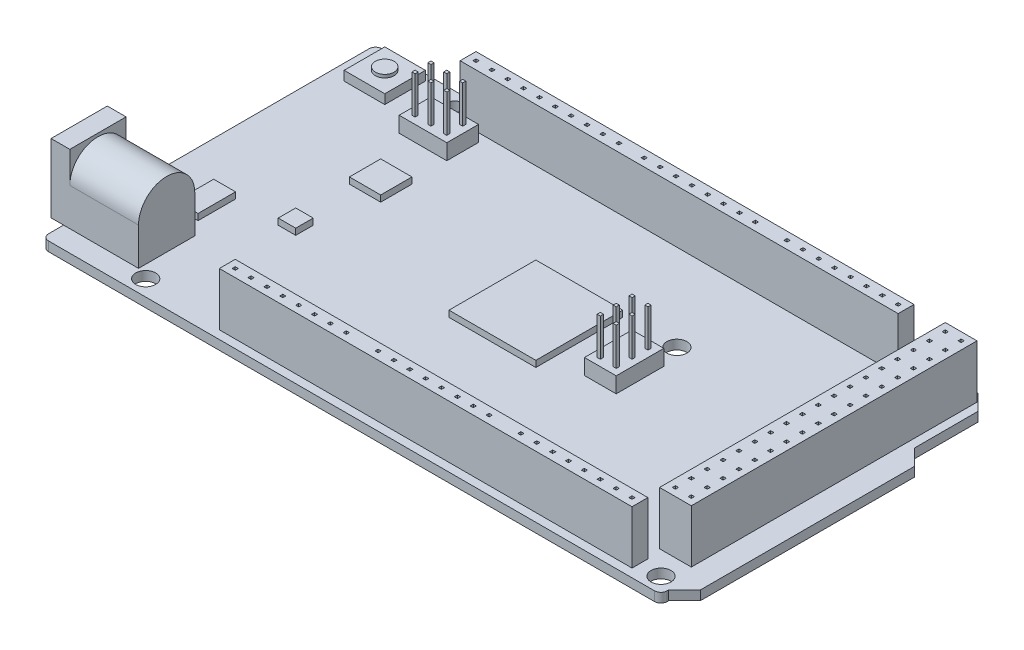
from build123d import *

# Parameters (mm, degrees)
BOSS_EXTRUDE1_DEPTH      = 1.5
FILLET1_R                = 1
SKETCH2_R                = 1.6
CUT_EXTRUDE1_DEPTH       = 59.477289609
SKETCH3_W                = 5.08
SKETCH3_H                = 45.72
BOSS_EXTRUDE2_DEPTH      = 8.5
SKETCH4_W                = 0.5
SKETCH4_H                = 0.5
CUT_EXTRUDE2_DEPTH       = 7
SKETCH6_W                = 9
SKETCH6_H                = 11
BOSS_EXTRUDE4_DEPTH      = 2
BOSS_EXTRUDE4_DEPTH_BACK = 1
SKETCH7_R                = 4.5
BOSS_EXTRUDE5_DEPTH      = 11
SKETCH8_W                = 11
SKETCH8_H                = 9
BOSS_EXTRUDE6_DEPTH      = 6
SKETCH11_W               = 13.9
SKETCH11_H               = 13.9
SKETCH11_W_2             = 5
SKETCH11_H_2             = 5
SKETCH11_W_3             = 2.8
SKETCH11_H_3             = 2.8
SKETCH11_W_4             = 3.5
SKETCH11_H_4             = 6
BOSS_EXTRUDE8_DEPTH      = 1
SKETCH12_R               = 3
CUT_EXTRUDE4_DEPTH       = 9.5
SKETCH13_R               = 1.25
BOSS_EXTRUDE9_DEPTH      = 7.5
FILLET2_R                = 1
SKETCH14_W               = 6.5
SKETCH14_H               = 6.5
BOSS_EXTRUDE10_DEPTH     = 1.5
SKETCH15_R               = 1.5
BOSS_EXTRUDE11_DEPTH     = 0.5
SKETCH16_W               = 5.08
SKETCH16_H               = 7.62
SKETCH16_W_2             = 7.62
SKETCH16_H_2             = 5.08
BOSS_EXTRUDE12_DEPTH     = 2.5
SKETCH17_W               = 0.5
SKETCH17_H               = 0.5
BOSS_EXTRUDE13_DEPTH     = 6


with BuildPart() as part:
    # Sketch1 → Boss-Extrude1 (new body)
    with BuildSketch(Plane(origin=(0, 0, 0), x_dir=(1, 0, 0), z_dir=(0, 1, 0))):
        Polygon((49.49, 24.11), (49.49, 13.95), (52.03, 11.41), (52.03, -22.85), (49.49, -25.39), (49.49, -26.65), (-49.49, -26.65), (-49.49, 26.65), (46.95, 26.65), align=None)
    extrude(amount=BOSS_EXTRUDE1_DEPTH)

    # Fillet1
    fillet1_edges = [part.edges().sort_by_distance(p)[0] for p in [
        (-49.49, 0.75, -26.65),
        (49.49, 0.75, 26.65),
        (-49.49, 0.75, 26.65),
    ]]
    fillet(fillet1_edges, radius=FILLET1_R)

    # Sketch2 → Cut-Extrude1 (cut, through all)
    with BuildSketch(Plane(origin=(0, 1.5, 0), x_dir=(1, 0, 0), z_dir=(0, 1, 0))):
        with Locations(Location((46.98, -24.11, 0), (0, 0, 270))):
            Circle(SKETCH2_R)
        with Locations(Location((40.62, 24.11, 0), (0, 0, 270))):
            Circle(SKETCH2_R)
        with Locations(Location((-34.26, 24.11, 0), (0, 0, 270))):
            Circle(SKETCH2_R)
        with Locations(Location((-35.49, -24.11, 0), (0, 0, 270))):
            Circle(SKETCH2_R)
        with Locations(Location((16.53, -19.03, 0), (0, 0, 270))):
            Circle(SKETCH2_R)
        with Locations(Location((16.53, 8.88, 0), (0, 0, 270))):
            Circle(SKETCH2_R)
    extrude(amount=-CUT_EXTRUDE1_DEPTH, mode=Mode.SUBTRACT)

    # Sketch3 → Boss-Extrude2 (add)
    with BuildSketch(Plane(origin=(0, 1.5, 0), x_dir=(1, 0, 0), z_dir=(0, 1, 0))):
        Polygon((-22.51, -22.76), (-2.19, -22.76), (0.35, -22.76), (20.67, -22.76), (23.21, -22.76), (43.53, -22.76), (43.53, -25.3), (23.21, -25.3), (20.67, -25.3), (0.35, -25.3), (-2.19, -25.3), (-22.51, -25.3), align=None)
        with Locations((45.6, 2.44)):
            Rectangle(SKETCH3_W, SKETCH3_H)
        Polygon((38.06, 25.3), (17.74, 25.3), (15.2, 25.3), (-5.12, 25.3), (-6.64, 25.3), (-32.04, 25.3), (-32.04, 22.76), (-6.64, 22.76), (-5.12, 22.76), (15.2, 22.76), (17.74, 22.76), (38.06, 22.76), align=None)
    extrude(amount=BOSS_EXTRUDE2_DEPTH)

    # Sketch4 → Cut-Extrude2 (cut)
    with BuildSketch(Plane(origin=(0, 10, 0), x_dir=(1, 0, 0), z_dir=(0, 1, 0))):
        with Locations((-21.24, -24.03)):
            Rectangle(SKETCH4_W, SKETCH4_H)
        with Locations((-18.7, -24.03)):
            Rectangle(SKETCH4_W, SKETCH4_H)
        with Locations((-16.16, -24.03)):
            Rectangle(SKETCH4_W, SKETCH4_H)
        with Locations((-13.62, -24.03)):
            Rectangle(SKETCH4_W, SKETCH4_H)
        with Locations((-11.08, -24.03)):
            Rectangle(SKETCH4_W, SKETCH4_H)
        with Locations((-8.54, -24.03)):
            Rectangle(SKETCH4_W, SKETCH4_H)
        with Locations((-6, -24.03)):
            Rectangle(SKETCH4_W, SKETCH4_H)
        with Locations((-3.46, -24.03)):
            Rectangle(SKETCH4_W, SKETCH4_H)
        with Locations((1.62, -24.03)):
            Rectangle(SKETCH4_W, SKETCH4_H)
        with Locations((4.16, -24.03)):
            Rectangle(SKETCH4_W, SKETCH4_H)
        with Locations((6.7, -24.03)):
            Rectangle(SKETCH4_W, SKETCH4_H)
        with Locations((9.24, -24.03)):
            Rectangle(SKETCH4_W, SKETCH4_H)
        with Locations((11.78, -24.03)):
            Rectangle(SKETCH4_W, SKETCH4_H)
        with Locations((14.32, -24.03)):
            Rectangle(SKETCH4_W, SKETCH4_H)
        with Locations((16.86, -24.03)):
            Rectangle(SKETCH4_W, SKETCH4_H)
        with Locations((19.4, -24.03)):
            Rectangle(SKETCH4_W, SKETCH4_H)
        with Locations((24.48, -24.03)):
            Rectangle(SKETCH4_W, SKETCH4_H)
        with Locations((27.02, -24.03)):
            Rectangle(SKETCH4_W, SKETCH4_H)
        with Locations((29.56, -24.03)):
            Rectangle(SKETCH4_W, SKETCH4_H)
        with Locations((32.1, -24.03)):
            Rectangle(SKETCH4_W, SKETCH4_H)
        with Locations((34.64, -24.03)):
            Rectangle(SKETCH4_W, SKETCH4_H)
        with Locations((37.18, -24.03)):
            Rectangle(SKETCH4_W, SKETCH4_H)
        with Locations((39.72, -24.03)):
            Rectangle(SKETCH4_W, SKETCH4_H)
        with Locations((42.26, -24.03)):
            Rectangle(SKETCH4_W, SKETCH4_H)
        with Locations((46.87, -19.15)):
            Rectangle(SKETCH4_W, SKETCH4_H)
        with Locations((44.33, -19.15)):
            Rectangle(SKETCH4_W, SKETCH4_H)
        with Locations((46.87, -16.61)):
            Rectangle(SKETCH4_W, SKETCH4_H)
        with Locations((44.33, -16.61)):
            Rectangle(SKETCH4_W, SKETCH4_H)
        with Locations((46.87, -14.07)):
            Rectangle(SKETCH4_W, SKETCH4_H)
        with Locations((44.33, -14.07)):
            Rectangle(SKETCH4_W, SKETCH4_H)
        with Locations((46.87, -11.53)):
            Rectangle(SKETCH4_W, SKETCH4_H)
        with Locations((44.33, -11.53)):
            Rectangle(SKETCH4_W, SKETCH4_H)
        with Locations((46.87, -8.99)):
            Rectangle(SKETCH4_W, SKETCH4_H)
        with Locations((44.33, -8.99)):
            Rectangle(SKETCH4_W, SKETCH4_H)
        with Locations((46.87, -6.45)):
            Rectangle(SKETCH4_W, SKETCH4_H)
        with Locations((44.33, -6.45)):
            Rectangle(SKETCH4_W, SKETCH4_H)
        with Locations((46.87, -3.91)):
            Rectangle(SKETCH4_W, SKETCH4_H)
        with Locations((44.33, -3.91)):
            Rectangle(SKETCH4_W, SKETCH4_H)
        with Locations((46.87, -1.37)):
            Rectangle(SKETCH4_W, SKETCH4_H)
        with Locations((44.33, -1.37)):
            Rectangle(SKETCH4_W, SKETCH4_H)
        with Locations((46.87, 1.17)):
            Rectangle(SKETCH4_W, SKETCH4_H)
        with Locations((44.33, 1.17)):
            Rectangle(SKETCH4_W, SKETCH4_H)
        with Locations((46.87, 3.71)):
            Rectangle(SKETCH4_W, SKETCH4_H)
        with Locations((44.33, 3.71)):
            Rectangle(SKETCH4_W, SKETCH4_H)
        with Locations((46.87, 6.25)):
            Rectangle(SKETCH4_W, SKETCH4_H)
        with Locations((44.33, 6.25)):
            Rectangle(SKETCH4_W, SKETCH4_H)
        with Locations((46.87, 8.79)):
            Rectangle(SKETCH4_W, SKETCH4_H)
        with Locations((44.33, 8.79)):
            Rectangle(SKETCH4_W, SKETCH4_H)
        with Locations((46.87, 11.33)):
            Rectangle(SKETCH4_W, SKETCH4_H)
        with Locations((44.33, 11.33)):
            Rectangle(SKETCH4_W, SKETCH4_H)
        with Locations((46.87, 13.87)):
            Rectangle(SKETCH4_W, SKETCH4_H)
        with Locations((44.33, 13.87)):
            Rectangle(SKETCH4_W, SKETCH4_H)
        with Locations((46.87, 16.41)):
            Rectangle(SKETCH4_W, SKETCH4_H)
        with Locations((44.33, 16.41)):
            Rectangle(SKETCH4_W, SKETCH4_H)
        with Locations((46.87, 18.95)):
            Rectangle(SKETCH4_W, SKETCH4_H)
        with Locations((44.33, 18.95)):
            Rectangle(SKETCH4_W, SKETCH4_H)
        with Locations((46.87, 21.49)):
            Rectangle(SKETCH4_W, SKETCH4_H)
        with Locations((44.33, 21.49)):
            Rectangle(SKETCH4_W, SKETCH4_H)
        with Locations((46.87, 24.03)):
            Rectangle(SKETCH4_W, SKETCH4_H)
        with Locations((44.33, 24.03)):
            Rectangle(SKETCH4_W, SKETCH4_H)
        with Locations((36.79, 24.03)):
            Rectangle(SKETCH4_W, SKETCH4_H)
        with Locations((34.25, 24.03)):
            Rectangle(SKETCH4_W, SKETCH4_H)
        with Locations((31.71, 24.03)):
            Rectangle(SKETCH4_W, SKETCH4_H)
        with Locations((29.17, 24.03)):
            Rectangle(SKETCH4_W, SKETCH4_H)
        with Locations((26.63, 24.03)):
            Rectangle(SKETCH4_W, SKETCH4_H)
        with Locations((24.09, 24.03)):
            Rectangle(SKETCH4_W, SKETCH4_H)
        with Locations((21.55, 24.03)):
            Rectangle(SKETCH4_W, SKETCH4_H)
        with Locations((19.01, 24.03)):
            Rectangle(SKETCH4_W, SKETCH4_H)
        with Locations((13.93, 24.03)):
            Rectangle(SKETCH4_W, SKETCH4_H)
        with Locations((11.39, 24.03)):
            Rectangle(SKETCH4_W, SKETCH4_H)
        with Locations((8.85, 24.03)):
            Rectangle(SKETCH4_W, SKETCH4_H)
        with Locations((6.31, 24.03)):
            Rectangle(SKETCH4_W, SKETCH4_H)
        with Locations((3.77, 24.03)):
            Rectangle(SKETCH4_W, SKETCH4_H)
        with Locations((1.23, 24.03)):
            Rectangle(SKETCH4_W, SKETCH4_H)
        with Locations((-1.31, 24.03)):
            Rectangle(SKETCH4_W, SKETCH4_H)
        with Locations((-3.85, 24.03)):
            Rectangle(SKETCH4_W, SKETCH4_H)
        with Locations((-7.91, 24.03)):
            Rectangle(SKETCH4_W, SKETCH4_H)
        with Locations((-10.45, 24.03)):
            Rectangle(SKETCH4_W, SKETCH4_H)
        with Locations((-12.99, 24.03)):
            Rectangle(SKETCH4_W, SKETCH4_H)
        with Locations((-15.53, 24.03)):
            Rectangle(SKETCH4_W, SKETCH4_H)
        with Locations((-18.07, 24.03)):
            Rectangle(SKETCH4_W, SKETCH4_H)
        with Locations((-20.61, 24.03)):
            Rectangle(SKETCH4_W, SKETCH4_H)
        with Locations((-23.15, 24.03)):
            Rectangle(SKETCH4_W, SKETCH4_H)
        with Locations((-25.69, 24.03)):
            Rectangle(SKETCH4_W, SKETCH4_H)
        with Locations((-28.23, 24.03)):
            Rectangle(SKETCH4_W, SKETCH4_H)
        with Locations((-30.77, 24.03)):
            Rectangle(SKETCH4_W, SKETCH4_H)
    extrude(amount=-CUT_EXTRUDE2_DEPTH, mode=Mode.SUBTRACT)



with BuildPart() as body_2:
    # Sketch6 → Boss-Extrude4 (new, two sides)
    with BuildSketch(Plane.ZY.offset(49.49)) as boss_extrude4_sk:
        with Locations((18.75, 7)):
            Rectangle(SKETCH6_W, SKETCH6_H)
    extrude(amount=BOSS_EXTRUDE4_DEPTH)
    extrude(boss_extrude4_sk.sketch, amount=-BOSS_EXTRUDE4_DEPTH_BACK)


with BuildPart() as part_1:
    add(part.part)

    add(body_2.part)  # Boss-Extrude5 merges body 2
    # Sketch7 → Boss-Extrude5 (add)
    with BuildSketch(Plane(origin=(-48.49, 0, 0), x_dir=(0, 0, -1), z_dir=(1, 0, 0))):
        with Locations((-18.75, 7.5)):
            Circle(SKETCH7_R)
    extrude(amount=BOSS_EXTRUDE5_DEPTH)

    # Sketch8 → Boss-Extrude6 (add)
    with BuildSketch(Plane(origin=(0, 1.5, 0), x_dir=(1, 0, 0), z_dir=(0, 1, 0))):
        with Locations((-42.99, -18.75)):
            Rectangle(SKETCH8_W, SKETCH8_H)
    extrude(amount=BOSS_EXTRUDE6_DEPTH)

    # Sketch11 → Boss-Extrude8 (add)
    with BuildSketch(Plane(origin=(0, 1.5, 0), x_dir=(1, 0, 0), z_dir=(0, 1, 0))):
        with Locations((1.09, 1.75)):
            Rectangle(SKETCH11_W, SKETCH11_H)
        with Locations((-29.79, 7.8)):
            Rectangle(SKETCH11_W_2, SKETCH11_H_2)
        with Locations((-30.89, -4.7)):
            Rectangle(SKETCH11_W_3, SKETCH11_H_3)
        with Locations((-41.090307387, -8.878300353)):
            Rectangle(SKETCH11_W_4, SKETCH11_H_4)
    extrude(amount=BOSS_EXTRUDE8_DEPTH)

    # Sketch12 → Cut-Extrude4 (cut)
    with BuildSketch(Plane.ZY.offset(51.49)):
        with Locations((18.75, 8)):
            Circle(SKETCH12_R)
    extrude(amount=-CUT_EXTRUDE4_DEPTH, mode=Mode.SUBTRACT)

    # Sketch13 → Boss-Extrude9 (add)
    with BuildSketch(Plane.ZY.offset(41.99)):
        with Locations((18.75, 8)):
            Circle(SKETCH13_R)
    extrude(amount=BOSS_EXTRUDE9_DEPTH)

    # Fillet2
    fillet2_edges = [part_1.edges().sort_by_distance(p)[0] for p in [
        (-49.49, 8, 17.5),
    ]]
    fillet(fillet2_edges, radius=FILLET2_R)

    # Sketch14 → Boss-Extrude10 (add)
    with BuildSketch(Plane(origin=(0, 1.5, 0), x_dir=(1, 0, 0), z_dir=(0, 1, 0))):
        with Locations((-43.74, 22.4)):
            Rectangle(SKETCH14_W, SKETCH14_H)
    extrude(amount=BOSS_EXTRUDE10_DEPTH)

    # Sketch15 → Boss-Extrude11 (add)
    with BuildSketch(Plane(origin=(0, 3, 0), x_dir=(1, 0, 0), z_dir=(0, 1, 0))):
        with Locations(Location((-43.74, 22.4, 0), (0, 0, 270))):
            Circle(SKETCH15_R)
    extrude(amount=BOSS_EXTRUDE11_DEPTH)

    # Sketch16 → Boss-Extrude12 (add)
    with BuildSketch(Plane(origin=(0, 1.5, 0), x_dir=(1, 0, 0), z_dir=(0, 1, 0))):
        with Locations((15.58, 1.39)):
            Rectangle(SKETCH16_W, SKETCH16_H)
        with Locations((-31.55, 18.87)):
            Rectangle(SKETCH16_W_2, SKETCH16_H_2)
    extrude(amount=BOSS_EXTRUDE12_DEPTH)

    # Sketch17 → Boss-Extrude13 (add)
    with BuildSketch(Plane(origin=(0, 4, 0), x_dir=(1, 0, 0), z_dir=(0, 1, 0))):
        with Locations((-34.09, 17.6)):
            Rectangle(SKETCH17_W, SKETCH17_H)
        with Locations((-34.09, 20.14)):
            Rectangle(SKETCH17_W, SKETCH17_H)
        with Locations((16.85, -1.15)):
            Rectangle(SKETCH17_W, SKETCH17_H)
        with Locations((14.31, -1.15)):
            Rectangle(SKETCH17_W, SKETCH17_H)
        with Locations((-31.55, 20.14)):
            Rectangle(SKETCH17_W, SKETCH17_H)
        with Locations((-31.55, 17.6)):
            Rectangle(SKETCH17_W, SKETCH17_H)
        with Locations((-29.01, 20.14)):
            Rectangle(SKETCH17_W, SKETCH17_H)
        with Locations((-29.01, 17.6)):
            Rectangle(SKETCH17_W, SKETCH17_H)
        with Locations((14.31, 1.39)):
            Rectangle(SKETCH17_W, SKETCH17_H)
        with Locations((16.85, 1.39)):
            Rectangle(SKETCH17_W, SKETCH17_H)
        with Locations((14.31, 3.93)):
            Rectangle(SKETCH17_W, SKETCH17_H)
        with Locations((16.85, 3.93)):
            Rectangle(SKETCH17_W, SKETCH17_H)
    extrude(amount=BOSS_EXTRUDE13_DEPTH)


solid = part_1.part
